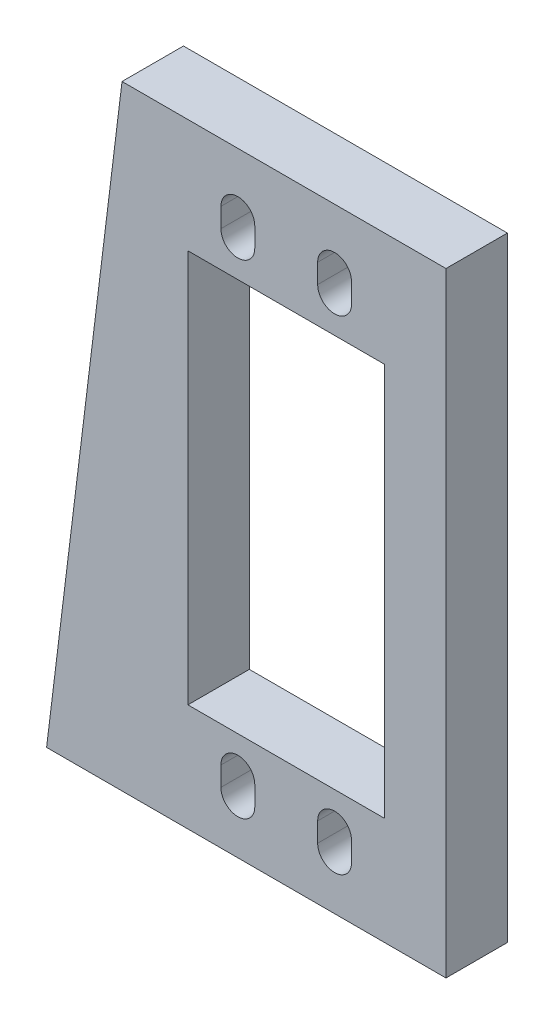
from build123d import *

# Parameters (mm, degrees)
SKETCH1_W           = 20.32
SKETCH1_H           = 40.64
BOSS_EXTRUDE1_DEPTH = 6.35


with BuildPart() as part:
    # Sketch1 → Boss-Extrude1 (new body)
    with BuildSketch(Plane.XY):
        Polygon((0, 0), (41.275, 0), (41.275, 63.5), (7.796819617, 63.5), align=None)
        with BuildLine():
            ThreePointArc((28.015, 5.4325), (29.765, 3.6825), (31.515, 5.4325))
            Line((31.515, 5.4325), (31.515, 7.4325))
            ThreePointArc((31.515, 7.4325), (29.765, 9.1825), (28.015, 7.4325))
            Line((28.015, 7.4325), (28.015, 5.4325))
        make_face(mode=Mode.SUBTRACT)
        with BuildLine():
            ThreePointArc((18.015, 5.4325), (19.765, 3.6825), (21.515, 5.4325))
            Line((21.515, 5.4325), (21.515, 7.4325))
            ThreePointArc((21.515, 7.4325), (19.765, 9.1825), (18.015, 7.4325))
            Line((18.015, 7.4325), (18.015, 5.4325))
        make_face(mode=Mode.SUBTRACT)
        with BuildLine():
            ThreePointArc((31.515, 57.4325), (29.765, 59.1825), (28.015, 57.4325))
            Line((28.015, 57.4325), (28.015, 55.4325))
            ThreePointArc((28.015, 55.4325), (29.765, 53.6825), (31.515, 55.4325))
            Line((31.515, 55.4325), (31.515, 57.4325))
        make_face(mode=Mode.SUBTRACT)
        with BuildLine():
            ThreePointArc((21.515, 57.4325), (19.765, 59.1825), (18.015, 57.4325))
            Line((18.015, 57.4325), (18.015, 55.4325))
            ThreePointArc((18.015, 55.4325), (19.765, 53.6825), (21.515, 55.4325))
            Line((21.515, 55.4325), (21.515, 57.4325))
        make_face(mode=Mode.SUBTRACT)
        with Locations((24.765, 31.4325)):
            Rectangle(SKETCH1_W, SKETCH1_H, mode=Mode.SUBTRACT)
    extrude(amount=BOSS_EXTRUDE1_DEPTH)


solid = part.part
